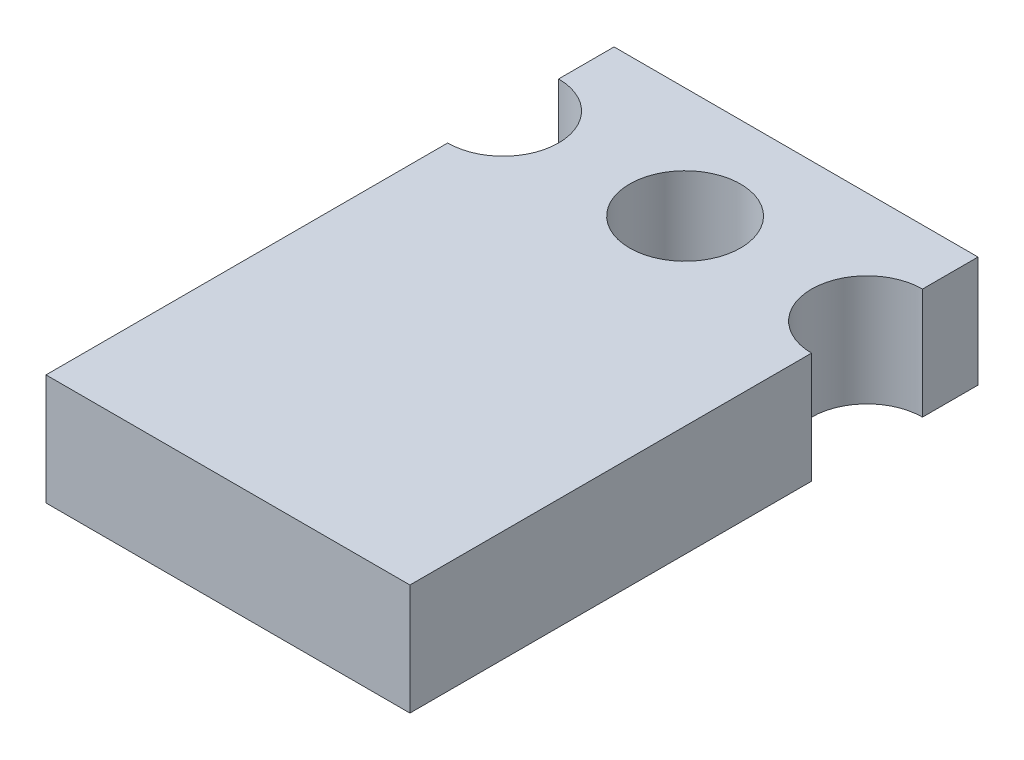
from build123d import *

# Parameters (mm, degrees)
SKETCH1_W           = 10.414
SKETCH1_H           = 16.256
BOSS_EXTRUDE1_DEPTH = 3.175
SKETCH2_R           = 1.5875
CUT_EXTRUDE1_DEPTH  = 3.175


with BuildPart() as part:
    # Sketch1 → Boss-Extrude1 (new body)
    with BuildSketch(Plane(origin=(0, 0, 0), x_dir=(1, 0, 0), z_dir=(0, 1, 0))):
        with Locations((5.207, 8.128)):
            Rectangle(SKETCH1_W, SKETCH1_H)
    extrude(amount=BOSS_EXTRUDE1_DEPTH)

    # Sketch2 → Cut-Extrude1 (cut)
    with BuildSketch(Plane(origin=(0, 3.175, 0), x_dir=(1, 0, 0), z_dir=(0, 1, 0))):
        with Locations((5.207, 13.081)):
            Circle(SKETCH2_R)
        with Locations((10.414, 13.081)):
            Circle(SKETCH2_R)
        with Locations((0, 13.081)):
            Circle(SKETCH2_R)
    extrude(amount=-CUT_EXTRUDE1_DEPTH, mode=Mode.SUBTRACT)


solid = part.part
